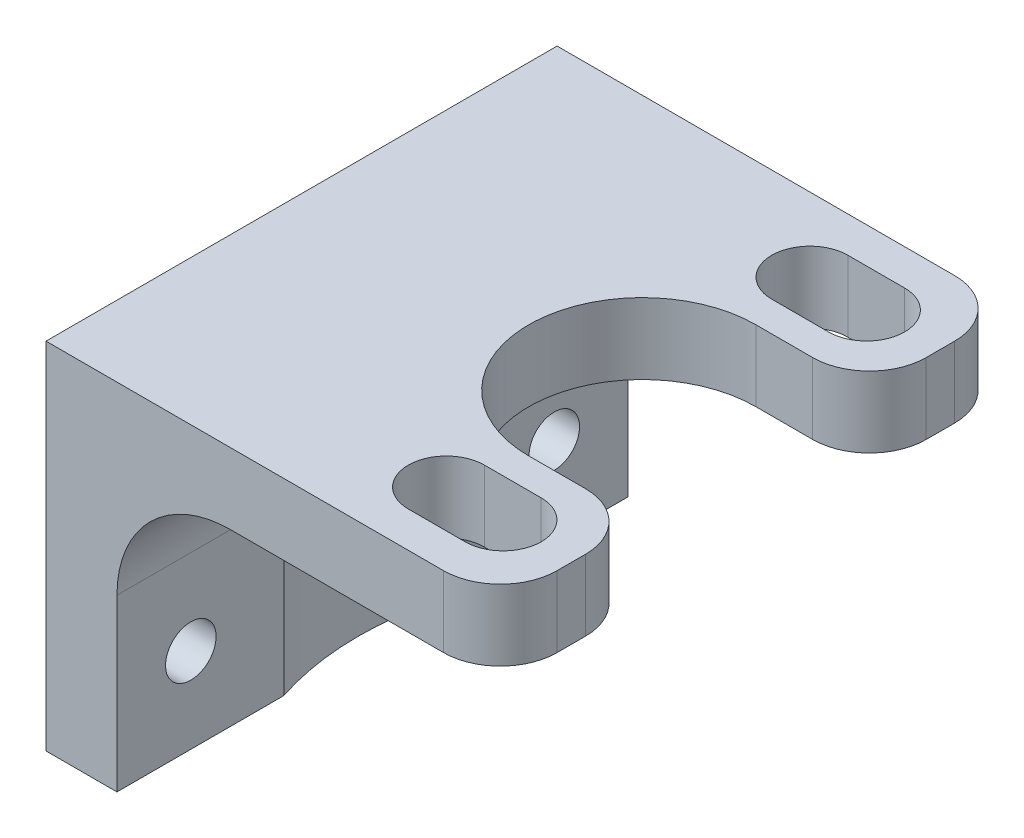
from build123d import *

# Parameters (mm, degrees)
SKETCH1_W             = 20.32
SKETCH1_H             = 22.86
BOSS_EXTRUDE1_DEPTH   = 3.175
FILLET1_R             = 2.54
FILLET2_R             = 2.54
CUT_EXTRUDE2_DEPTH    = 4.175
FILLET3_R             = 2.54
FILLET4_R             = 2.54
SKETCH4_W             = 3.175
SKETCH4_H             = 22.86
BOSS_EXTRUDE2_DEPTH   = 12.7
FILLET6_R             = 5.08
SKETCH5_R             = 12.7
CUT_EXTRUDE4_DEPTH    = 13.7
F_4_40_TAPPED_HOLE3_D = 2.2606
CUT_EXTRUDE6_DEPTH    = 16.8750001


with BuildPart() as part:
    # Sketch1 → Boss-Extrude1 (new body)
    with BuildSketch(Plane(origin=(0, 0, 0), x_dir=(1, 0, 0), z_dir=(0, 1, 0))):
        Rectangle(SKETCH1_W, SKETCH1_H)
    extrude(amount=BOSS_EXTRUDE1_DEPTH)

    # Fillet1
    fillet1_edges = [part.edges().sort_by_distance(p)[0] for p in [
        (10.16, 1.5875, -11.43),
    ]]
    fillet(fillet1_edges, radius=FILLET1_R)

    # Fillet2
    fillet2_edges = [part.edges().sort_by_distance(p)[0] for p in [
        (10.16, 1.5875, 11.43),
    ]]
    fillet(fillet2_edges, radius=FILLET2_R)

    # Sketch2 → Cut-Extrude2 (cut, through all)
    with BuildSketch(Plane.XZ):
        with BuildLine():
            Line((5.08, -5.08), (10.16, -5.08))
            Line((10.16, -5.08), (10.16, 5.08))
            Line((10.16, 5.08), (5.08, 5.08))
            ThreePointArc((5.08, 5.08), (0, 0), (5.08, -5.08))
        make_face()
    extrude(amount=-CUT_EXTRUDE2_DEPTH, mode=Mode.SUBTRACT)

    # Fillet3
    fillet3_edges = [part.edges().sort_by_distance(p)[0] for p in [
        (10.16, 1.5875, 5.08),
    ]]
    fillet(fillet3_edges, radius=FILLET3_R)

    # Fillet4
    fillet4_edges = [part.edges().sort_by_distance(p)[0] for p in [
        (10.16, 1.5875, -5.08),
    ]]
    fillet(fillet4_edges, radius=FILLET4_R)

    # Sketch4 → Boss-Extrude2 (add)
    with BuildSketch(Plane.XZ):
        with Locations((-8.5725, 0)):
            Rectangle(SKETCH4_W, SKETCH4_H)
    extrude(amount=BOSS_EXTRUDE2_DEPTH)

    # Fillet6
    fillet6_edges = [part.edges().sort_by_distance(p)[0] for p in [
        (-6.985, 0, 0),
    ]]
    fillet(fillet6_edges, radius=FILLET6_R)

    # Sketch5 → Cut-Extrude4 (cut, through all)
    with BuildSketch(Plane.XZ):
        with Locations((5.08, 0)):
            Circle(SKETCH5_R)
    extrude(amount=CUT_EXTRUDE4_DEPTH, mode=Mode.SUBTRACT)

    # #4-40 Tapped Hole3 (through all)
    with Locations(Plane(origin=(-6.985, 0, 0), x_dir=(0, 0, -1), z_dir=(1, 0, 0))):
        with Locations((-8.128, -8.89), (8.128, -8.89)):
            Hole(F_4_40_TAPPED_HOLE3_D / 2)

    # Sketch11 → Cut-Extrude6 (cut, through all)
    with BuildSketch(Plane(origin=(0, 3.175, 0), x_dir=(1, 0, 0), z_dir=(0, 1, 0))):
        with BuildLine():
            Line((6.985, 9.8298), (4.445, 9.8298))
            ThreePointArc((4.445, 9.8298), (2.7432, 8.128), (4.445, 6.4262))
            Line((4.445, 6.4262), (6.985, 6.4262))
            ThreePointArc((6.985, 6.4262), (8.6868, 8.128), (6.985, 9.8298))
        make_face()
        with BuildLine():
            Line((4.445, -6.4262), (6.985, -6.4262))
            ThreePointArc((6.985, -6.4262), (8.6868, -8.128), (6.985, -9.8298))
            Line((6.985, -9.8298), (4.445, -9.8298))
            ThreePointArc((4.445, -9.8298), (2.7432, -8.128), (4.445, -6.4262))
        make_face()
    extrude(amount=-CUT_EXTRUDE6_DEPTH, mode=Mode.SUBTRACT)


solid = part.part
